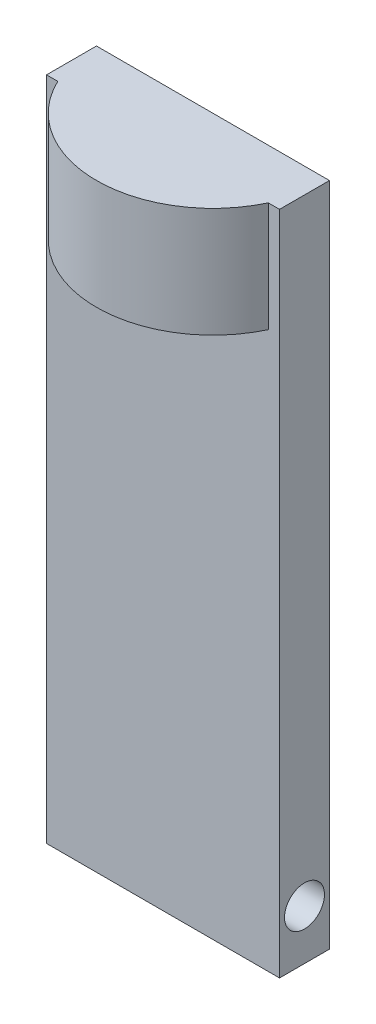
from build123d import *

# Parameters (mm, degrees)
SKETCH1_W           = 70
SKETCH1_H           = 200
BOSS_EXTRUDE4_DEPTH = 15
SKETCH9_R           = 6
CUT_EXTRUDE1_DEPTH  = 71
BOSS_EXTRUDE5_DEPTH = 33


with BuildPart() as part:
    # Sketch1 → Boss-Extrude4 (new body)
    with BuildSketch(Plane.XY):
        Rectangle(SKETCH1_W, SKETCH1_H)
    extrude(amount=BOSS_EXTRUDE4_DEPTH)

    # Sketch9 → Cut-Extrude1 (cut, through all)
    with BuildSketch(Plane(origin=(35, 0, 0), x_dir=(0, 0, -1), z_dir=(1, 0, 0))):
        with Locations((-7.5, -85)):
            Circle(SKETCH9_R)
    extrude(amount=-CUT_EXTRUDE1_DEPTH, mode=Mode.SUBTRACT)

    # Sketch10 → Boss-Extrude5 (add)
    with BuildSketch(Plane(origin=(0, 100, 0), x_dir=(1, 0, 0), z_dir=(0, 1, 0))):
        with BuildLine():
            Line((31.622776602, -15), (-31.622776602, -15))
            ThreePointArc((-31.622776602, -15), (0, -35), (31.622776602, -15))
        make_face()
    extrude(amount=-BOSS_EXTRUDE5_DEPTH)


solid = part.part
